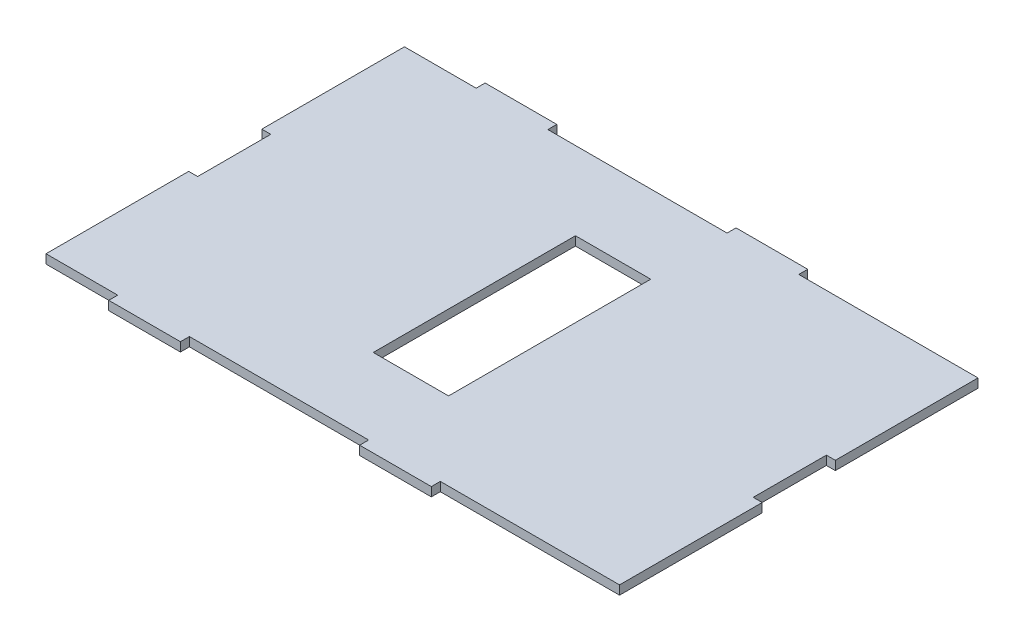
from build123d import *

# Parameters (mm, degrees)
SKETCH1_W           = 203.2
SKETCH1_H           = 127
BOSS_EXTRUDE1_DEPTH = 3.175
SKETCH2_W           = 25.4
SKETCH2_H           = 3.175
BOSS_EXTRUDE2_DEPTH = 3.175
SKETCH3_W           = 25.4
SKETCH3_H           = 3.175
BOSS_EXTRUDE3_DEPTH = 3.175
SKETCH4_W           = 25.908
SKETCH4_H           = 3.175
CUT_EXTRUDE1_DEPTH  = 3.175
SKETCH5_W           = 25.908
SKETCH5_H           = 3.175
CUT_EXTRUDE2_DEPTH  = 3.175
SKETCH7_W           = 26.67
SKETCH7_H           = 71.628
CUT_EXTRUDE3_DEPTH  = 3.175


with BuildPart() as part:
    # Sketch1 → Boss-Extrude1 (new body)
    with BuildSketch(Plane(origin=(0, 0, 0), x_dir=(1, 0, 0), z_dir=(0, 1, 0))):
        with Locations((94.089247312, -24.546505376)):
            Rectangle(SKETCH1_W, SKETCH1_H)
    extrude(amount=BOSS_EXTRUDE1_DEPTH)

    # Sketch2 → Boss-Extrude2 (add)
    with BuildSketch(Plane.XY.offset(88.046505376)):
        with Locations((119.489247312, 1.5875)):
            Rectangle(SKETCH2_W, SKETCH2_H)
        with Locations((30.589247312, 1.5875)):
            Rectangle(SKETCH2_W, SKETCH2_H)
    extrude(amount=BOSS_EXTRUDE2_DEPTH)

    # Sketch3 → Boss-Extrude3 (add)
    with BuildSketch(Plane(origin=(0, 0, -38.953494624), x_dir=(-1, 0, 0), z_dir=(0, 0, -1))):
        with Locations((-119.489247312, 1.5875)):
            Rectangle(SKETCH3_W, SKETCH3_H)
        with Locations((-30.589247312, 1.5875)):
            Rectangle(SKETCH3_W, SKETCH3_H)
    extrude(amount=BOSS_EXTRUDE3_DEPTH)

    # Sketch4 → Cut-Extrude1 (cut)
    with BuildSketch(Plane(origin=(195.689247312, 0, 0), x_dir=(0, 0, -1), z_dir=(1, 0, 0))):
        with Locations((-24.546505376, 1.5875)):
            Rectangle(SKETCH4_W, SKETCH4_H)
    extrude(amount=-CUT_EXTRUDE1_DEPTH, mode=Mode.SUBTRACT)

    # Sketch5 → Cut-Extrude2 (cut)
    with BuildSketch(Plane.ZY.offset(7.510752688)):
        with Locations((24.546505376, 1.5875)):
            Rectangle(SKETCH5_W, SKETCH5_H)
    extrude(amount=-CUT_EXTRUDE2_DEPTH, mode=Mode.SUBTRACT)

    # Sketch7 → Cut-Extrude3 (cut)
    with BuildSketch(Plane(origin=(0, 3.175, 0), x_dir=(1, 0, 0), z_dir=(0, 1, 0))):
        with Locations((94.089247312, -24.546505376)):
            Rectangle(SKETCH7_W, SKETCH7_H)
    extrude(amount=-CUT_EXTRUDE3_DEPTH, mode=Mode.SUBTRACT)


solid = part.part
